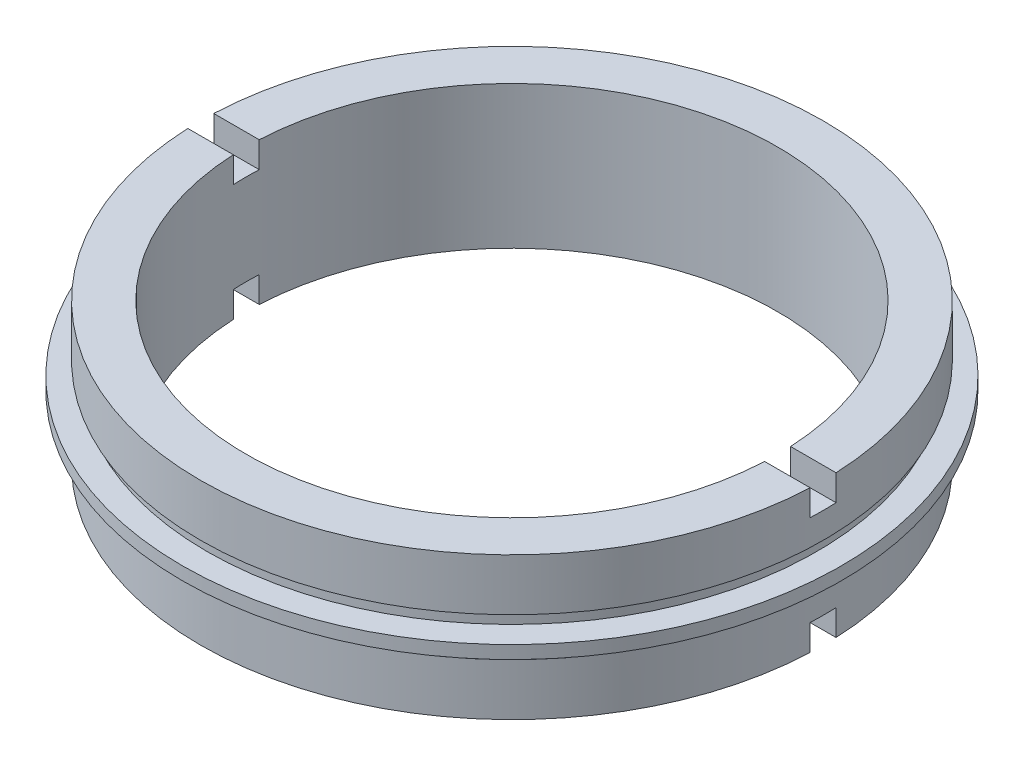
from build123d import *

# Parameters (mm, degrees)
SKETCH_2_W          = 2
SKETCH_2_H          = 4.593987872
SKETCH_2_H_2        = 6.667892238
CUT_EXTRUDE_1_DEPTH = 39.5


with BuildPart() as part:
    # 草图1 → 旋转1 (revolve)
    with BuildSketch(Plane.XY, mode=Mode.PRIVATE) as revolve_1_sk:
        Polygon((-20.5, 11), (-24, 11), (-24, 7), (-23.5, 7), (-23.5, 6), (-25.4, 6), (-25.4, 5), (-23.5, 5), (-23.5, 4), (-24, 4), (-24, 0), (-20.5, 0), align=None)
    revolve(revolve_1_sk.sketch.rotate(Axis((0, 22.677499451, 0), (0, -1, 0)), 270), axis=Axis((0, 22.677499451, 0), (0, -1, 0)))  # turned: the seam where the file's is

    # 草图2 → 切除-拉伸1 (cut, symmetric)
    with BuildSketch(Plane(origin=(0, 0, 0), x_dir=(0, 0, -1), z_dir=(1, 0, 0))):
        with Locations((0, 11.296993936)):
            Rectangle(SKETCH_2_W, SKETCH_2_H)
        with Locations((0, -1.333946119)):
            Rectangle(SKETCH_2_W, SKETCH_2_H_2)
    extrude(amount=CUT_EXTRUDE_1_DEPTH, both=True, mode=Mode.SUBTRACT)


solid = part.part
